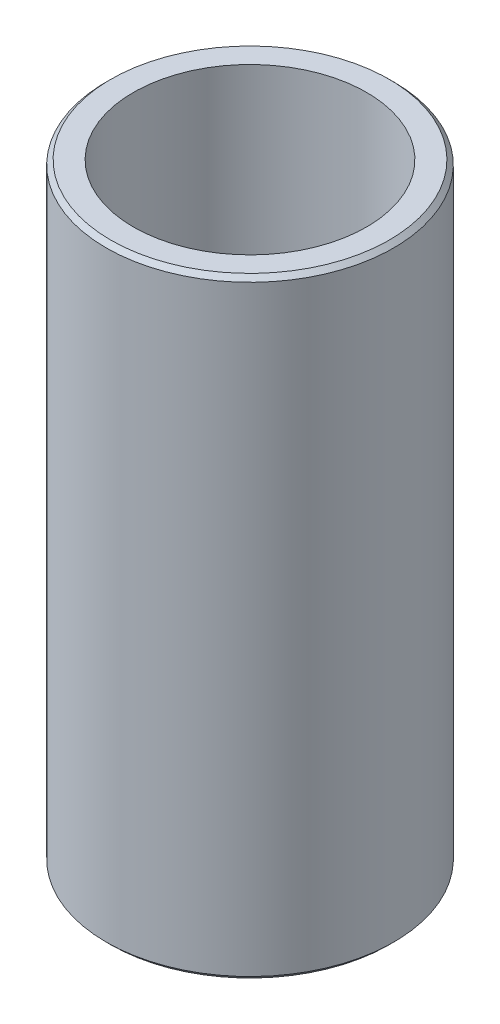
from build123d import *

# Parameters (mm, degrees)
SKETCH1_R           = 7.94
SKETCH1_R_2         = 6.44
BOSS_EXTRUDE1_DEPTH = 33.7
CHAMFER1_SIZE       = 0.25


with BuildPart() as part:
    # Sketch1 → Boss-Extrude1 (new body)
    with BuildSketch(Plane(origin=(0, 0, 0), x_dir=(1, 0, 0), z_dir=(0, 1, 0))):
        Circle(SKETCH1_R)
        Circle(SKETCH1_R_2, mode=Mode.SUBTRACT)
    extrude(amount=BOSS_EXTRUDE1_DEPTH)

    # Chamfer1
    chamfer1_edges = [part.edges().sort_by_distance(p)[0] for p in [
        (-7.94, 0, 0),
        (-7.94, 33.7, 0),
    ]]
    chamfer(chamfer1_edges, length=CHAMFER1_SIZE)


solid = part.part
